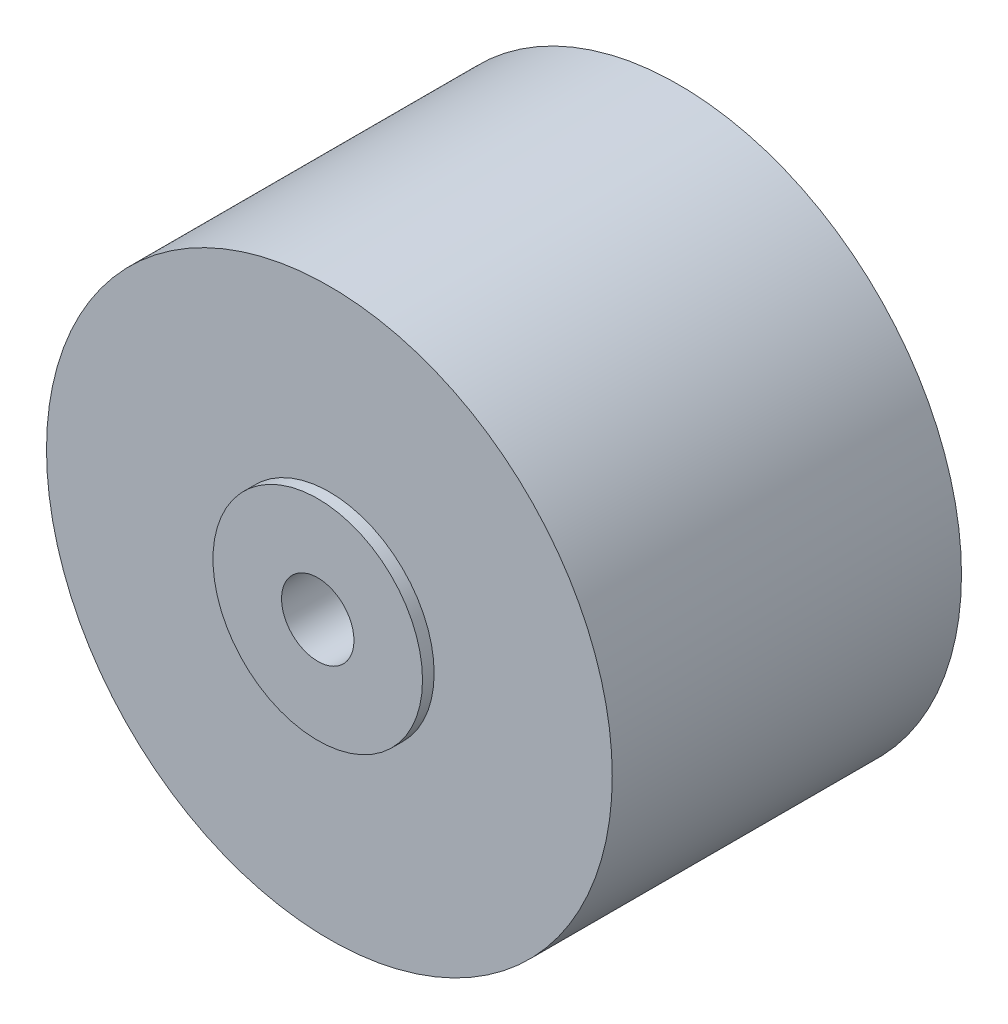
from build123d import *

# Parameters (mm, degrees)
ESBO_O1_R                  = 12.15
RESSALTO_EXTRUS_O1_DEPTH   = 15
ESBO_O2_R                  = 4.5
RESSALTO_EXTRUS_O2_DEPTH   = 15.5
ESBO_O3_R                  = 1.554984666
CORTE_EXTRUS_O1_DEPTH      = 19.5
CORTE_EXTRUS_O1_DEPTH_BACK = 15.5


with BuildPart() as part:
    # Esboço1 → Ressalto-extrusão1 (new body)
    with BuildSketch(Plane.XY):
        Circle(ESBO_O1_R)
    extrude(amount=RESSALTO_EXTRUS_O1_DEPTH)

    # Esboço2 → Ressalto-extrusão2 (add)
    with BuildSketch(Plane.XY):
        Circle(ESBO_O2_R)
    extrude(amount=RESSALTO_EXTRUS_O2_DEPTH)

    # Esboço3 → Corte-extrusão1 (cut, two sides)
    with BuildSketch(Plane.XY) as corte_extrus_o1_sk:
        Circle(ESBO_O3_R)
    extrude(amount=CORTE_EXTRUS_O1_DEPTH, mode=Mode.SUBTRACT)
    extrude(corte_extrus_o1_sk.sketch, amount=-CORTE_EXTRUS_O1_DEPTH_BACK, mode=Mode.SUBTRACT)


solid = part.part
